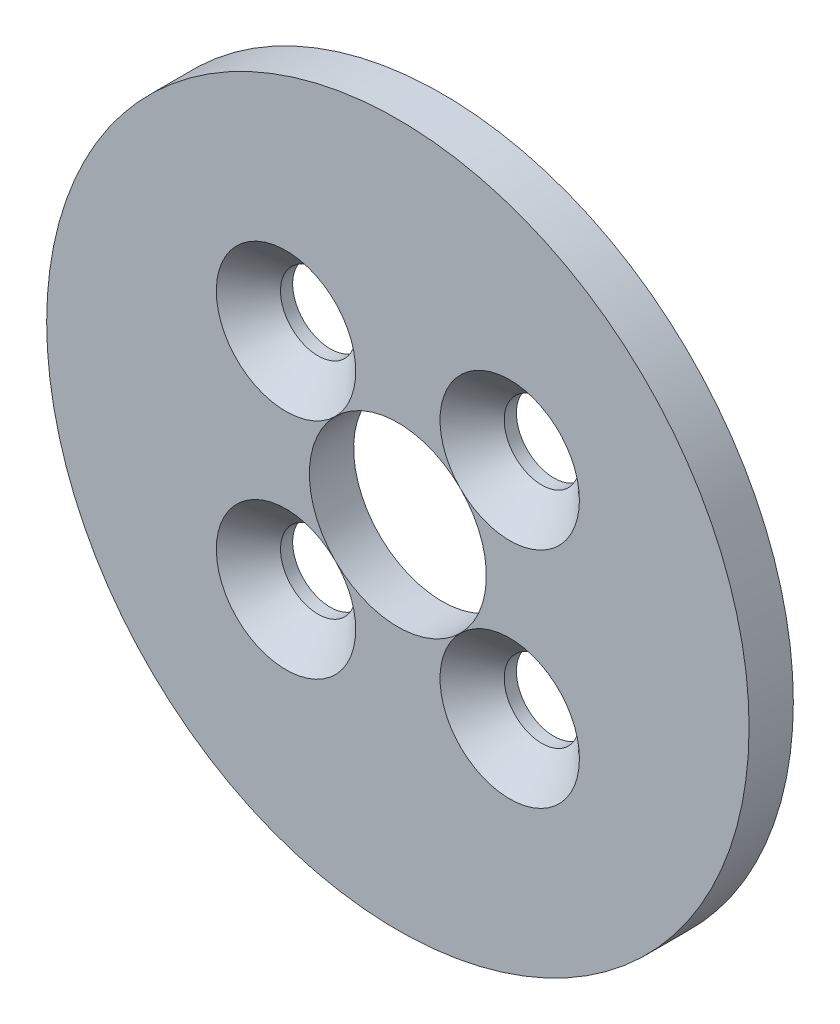
from build123d import *

# Parameters (mm, degrees)
SKETCH2_R                                      = 15.875
SKETCH2_R_2                                    = 1.7
SKETCH2_R_3                                    = 4
BOSS_EXTRUDE1_DEPTH                            = 2
CSK_FOR_M3_FLAT_HEAD_MACHINE_SCREW2_AT_2_COUNT = 2
CSK_FOR_M3_FLAT_HEAD_MACHINE_SCREW2_AT_2_PITCH = 10.111626971
CSK_FOR_M3_FLAT_HEAD_MACHINE_SCREW2_AT_3_COUNT = 2
CSK_FOR_M3_FLAT_HEAD_MACHINE_SCREW2_AT_3_PITCH = 14.3
CSK_FOR_M3_FLAT_HEAD_MACHINE_SCREW2_AT_4_COUNT = 2
CSK_FOR_M3_FLAT_HEAD_MACHINE_SCREW2_AT_4_PITCH = 10.111626971


with BuildPart() as part:
    # Sketch2 → Boss-Extrude1 (new body)
    with BuildSketch(Plane.XY):
        with Locations((-160.606756626, 98.885631483)):
            Circle(SKETCH2_R)
        with Locations((-165.662570112, 103.941444968)):
            Circle(SKETCH2_R_2, mode=Mode.SUBTRACT)
        with Locations((-155.550943141, 103.941444968)):
            Circle(SKETCH2_R_2, mode=Mode.SUBTRACT)
        with Locations((-155.550943141, 93.829817997)):
            Circle(SKETCH2_R_2, mode=Mode.SUBTRACT)
        with Locations((-165.662570112, 93.829817997)):
            Circle(SKETCH2_R_2, mode=Mode.SUBTRACT)
        with Locations((-160.606756626, 98.885631483)):
            Circle(SKETCH2_R_3, mode=Mode.SUBTRACT)
    extrude(amount=BOSS_EXTRUDE1_DEPTH)

    # Sketch4 → CSK for M3 Flat Head Machine Screw2 (revolve, cut)
    with BuildSketch(Plane(origin=(-165.662570112, 103.941444968, 2), x_dir=(0, -1, 0), z_dir=(1, 0, 0))):
        Polygon((0, 0), (0, 2), (1.7, 2), (1.7, 1.45), (3.15, 0), align=None)
    csk_for_m3_flat_head_machine_screw2 = revolve(axis=Axis((-165.662570112, 103.941444968, 8.35), (0, 0, -1)), mode=Mode.SUBTRACT)

    # CSK for M3 Flat Head Machine Screw2 at 2: CSK for M3 Flat Head Machine Screw2 ×2
    with Locations(*[(i * CSK_FOR_M3_FLAT_HEAD_MACHINE_SCREW2_AT_2_PITCH, 0, 0) for i in range(1, CSK_FOR_M3_FLAT_HEAD_MACHINE_SCREW2_AT_2_COUNT)]):
        add(csk_for_m3_flat_head_machine_screw2, mode=Mode.SUBTRACT)

    # CSK for M3 Flat Head Machine Screw2 at 3: CSK for M3 Flat Head Machine Screw2 ×2
    with Locations(*[Vector(0.707106781, -0.707106781, 0) * (i * CSK_FOR_M3_FLAT_HEAD_MACHINE_SCREW2_AT_3_PITCH) for i in range(1, CSK_FOR_M3_FLAT_HEAD_MACHINE_SCREW2_AT_3_COUNT)]):
        add(csk_for_m3_flat_head_machine_screw2, mode=Mode.SUBTRACT)

    # CSK for M3 Flat Head Machine Screw2 at 4: CSK for M3 Flat Head Machine Screw2 ×2
    with Locations(*[(0, -i * CSK_FOR_M3_FLAT_HEAD_MACHINE_SCREW2_AT_4_PITCH, 0) for i in range(1, CSK_FOR_M3_FLAT_HEAD_MACHINE_SCREW2_AT_4_COUNT)]):
        add(csk_for_m3_flat_head_machine_screw2, mode=Mode.SUBTRACT)


solid = part.part
